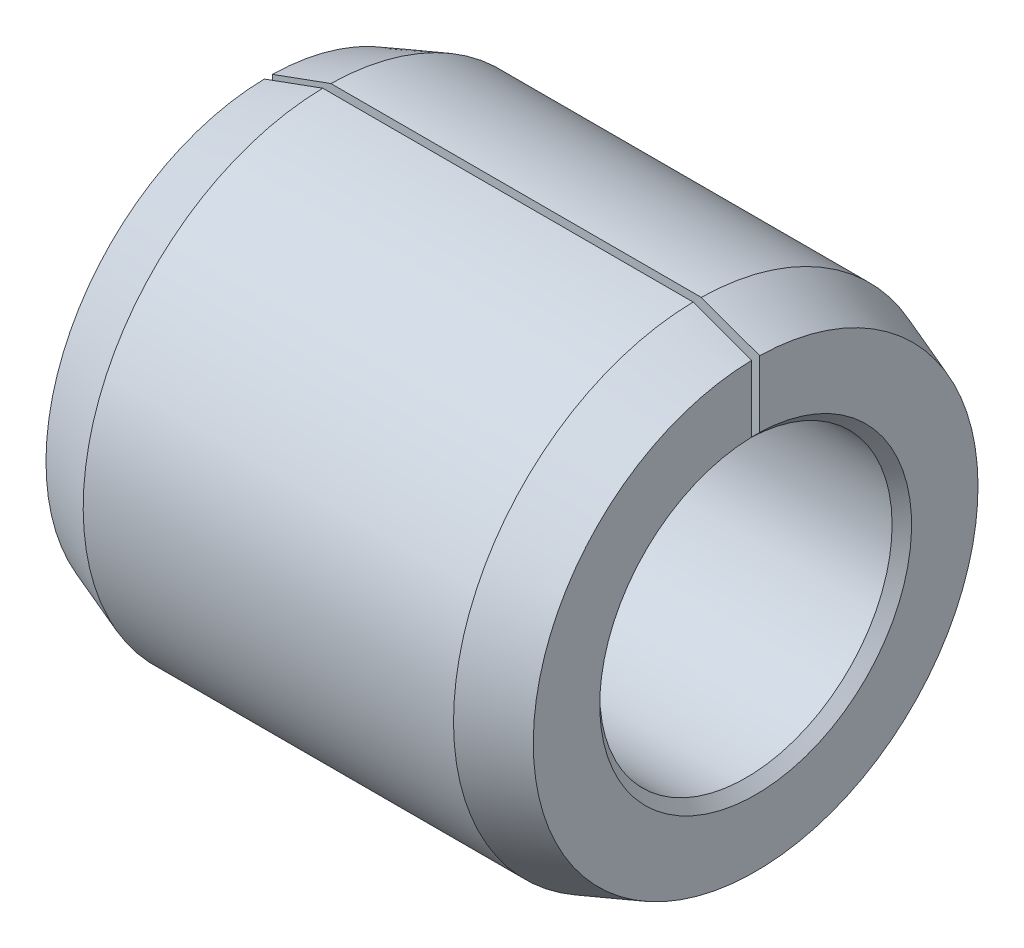
from build123d import *

# Parameters (mm, degrees)
SKETCH_2_W          = 0.083333334
SKETCH_2_H          = 2.5
CUT_EXTRUDE_1_DEPTH = 6


with BuildPart() as part:
    # 草图1 → 旋转1 (revolve)
    with BuildSketch(Plane.XY):
        Polygon((0.6, 2.5), (4.4, 2.5), (5, 2.281617859), (5, 1.6), (4.9, 1.5), (0.1, 1.5), (0, 1.6), (0, 2.281617859), align=None)
    revolve(axis=Axis((0, 0, 0), (1, 0, 0)))

    # 草图2 → 切除-拉伸1 (cut, through all)
    with BuildSketch(Plane(origin=(0, 0, 0), x_dir=(0, 0, -1), z_dir=(1, 0, 0))):
        with Locations((0, 1.25)):
            Rectangle(SKETCH_2_W, SKETCH_2_H)
    extrude(amount=CUT_EXTRUDE_1_DEPTH, mode=Mode.SUBTRACT)


solid = part.part
